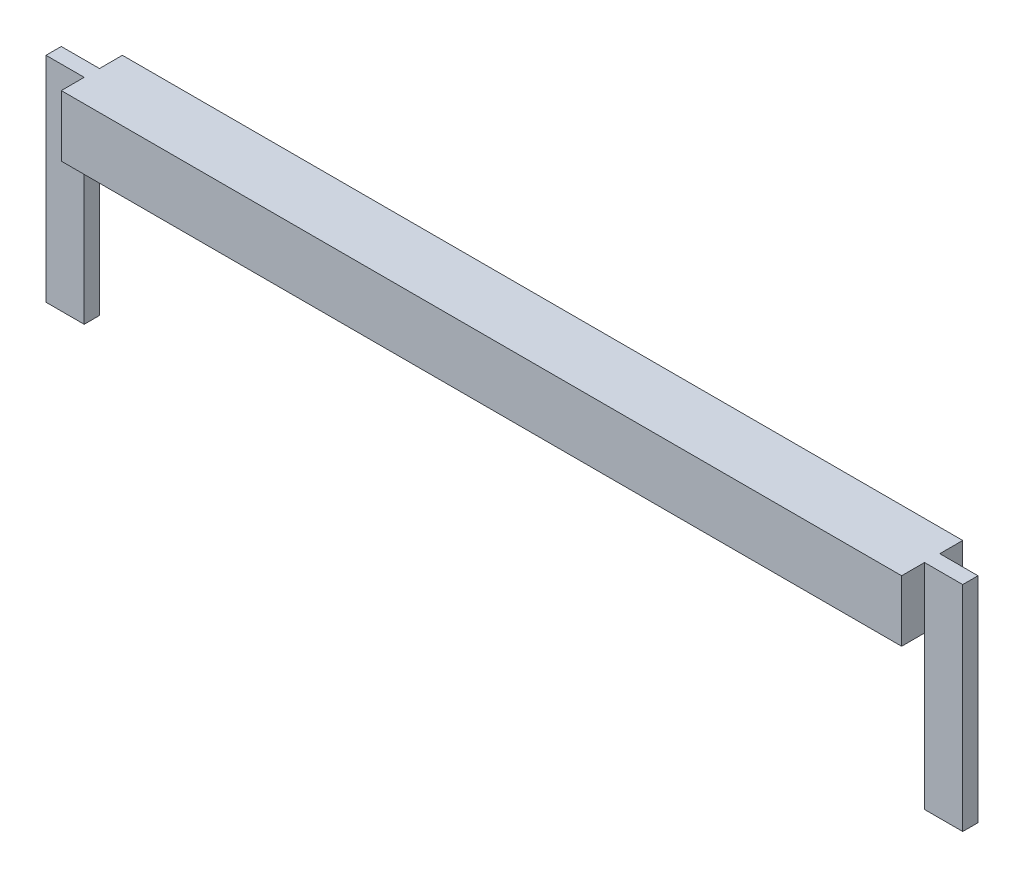
from build123d import *

# Parameters (mm, degrees)
SKETCH1_W                = 30
SKETCH1_H                = 2
BOSS_EXTRUDE2_DEPTH      = 0.5
SKETCH2_W                = 27.5
SKETCH2_H                = 2
BOSS_EXTRUDE4_DEPTH      = 0.75
BOSS_EXTRUDE4_DEPTH_BACK = 1.25
SKETCH3_W                = 1.25
SKETCH3_H                = 0.5
BOSS_EXTRUDE5_DEPTH      = 5
SKETCH4_W                = 1.25
SKETCH4_H                = 0.5
BOSS_EXTRUDE6_DEPTH      = 5


with BuildPart() as part:
    # Sketch1 → Boss-Extrude2 (new body)
    with BuildSketch(Plane.XY):
        with Locations((15, 1)):
            Rectangle(SKETCH1_W, SKETCH1_H)
    extrude(amount=BOSS_EXTRUDE2_DEPTH)

    # Sketch2 → Boss-Extrude4 (add, two sides)
    with BuildSketch(Plane.XY.offset(0.5)) as boss_extrude4_sk:
        with Locations((15, 1)):
            Rectangle(SKETCH2_W, SKETCH2_H)
    extrude(amount=BOSS_EXTRUDE4_DEPTH)
    extrude(boss_extrude4_sk.sketch, amount=-BOSS_EXTRUDE4_DEPTH_BACK)

    # Sketch3 → Boss-Extrude5 (add)
    with BuildSketch(Plane.XZ):
        with Locations((0.625, 0.25)):
            Rectangle(SKETCH3_W, SKETCH3_H)
    extrude(amount=BOSS_EXTRUDE5_DEPTH)

    # Sketch4 → Boss-Extrude6 (add)
    with BuildSketch(Plane(origin=(0, 0, 0), x_dir=(-1, 0, 0), z_dir=(0, -1, 0))):
        with Locations((-29.375, -0.25)):
            Rectangle(SKETCH4_W, SKETCH4_H)
    extrude(amount=BOSS_EXTRUDE6_DEPTH)


solid = part.part
